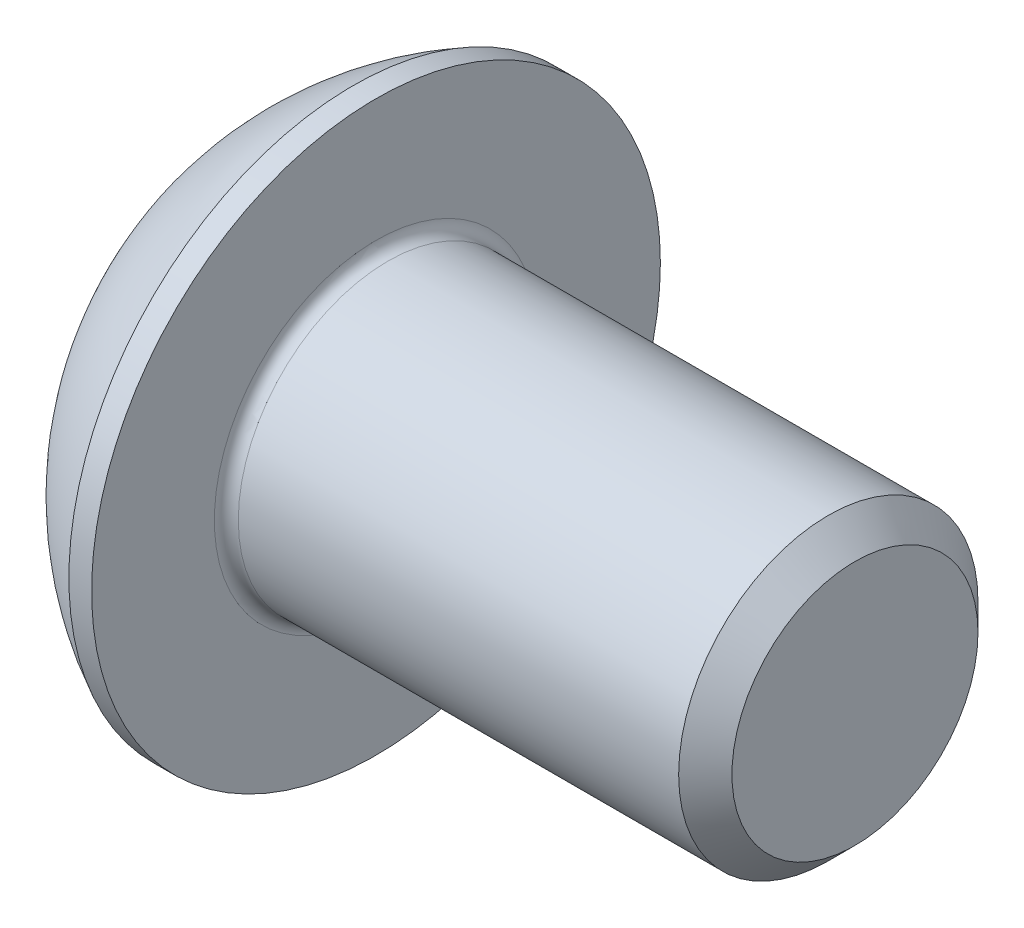
from build123d import *

# Parameters (mm, degrees)
CHAMFER_2_R = 0.2
HEX_2_DEPTH = 1.56


with BuildPart() as part:
    # Эскиз1 → Body (revolve)
    with BuildSketch(Plane.XY):
        with BuildLine():
            Line((0, 2.375), (0, 0))
            Line((0, 0), (10.75, 0))
            Line((10.75, 0), (10.75, 2.055))
            Line((10.75, 2.055), (10.305, 2.5))
            Line((10.305, 2.5), (2.75, 2.5))
            Line((2.75, 2.5), (2.75, 4.75))
            Line((2.75, 4.75), (2.370164642, 4.75))
            ThreePointArc((2.370164642, 4.75), (0.992749859, 3.754440885), (0, 2.375))
        make_face()
    revolve(axis=Axis((-3.643489966, 0, 0), (-1, 0, 0)))

    # Chamfer 2
    chamfer_2_edges = [part.edges().sort_by_distance(p)[0] for p in [
        (2.75, -2.5, 0),
    ]]
    fillet(chamfer_2_edges, radius=CHAMFER_2_R)

    # Эскиз2 → Hole (revolve, cut)
    with BuildSketch(Plane.XY):
        Polygon((0, 0), (0, 1.5), (1.56, 1.5), (2.426025404, 0), align=None)
    revolve(axis=Axis((2.426025404, 0, 0), (-1, 0, 0)), mode=Mode.SUBTRACT)

    # Эскиз3 → Hex 2 (cut)
    with BuildSketch(Plane.ZY):
        Polygon((-1.5, -0.866025404), (0, -1.732050808), (1.5, -0.866025404), (1.5, 0.866025404), (0, 1.732050808), (-1.5, 0.866025404), align=None)
    extrude(amount=-HEX_2_DEPTH, mode=Mode.SUBTRACT)


solid = part.part
